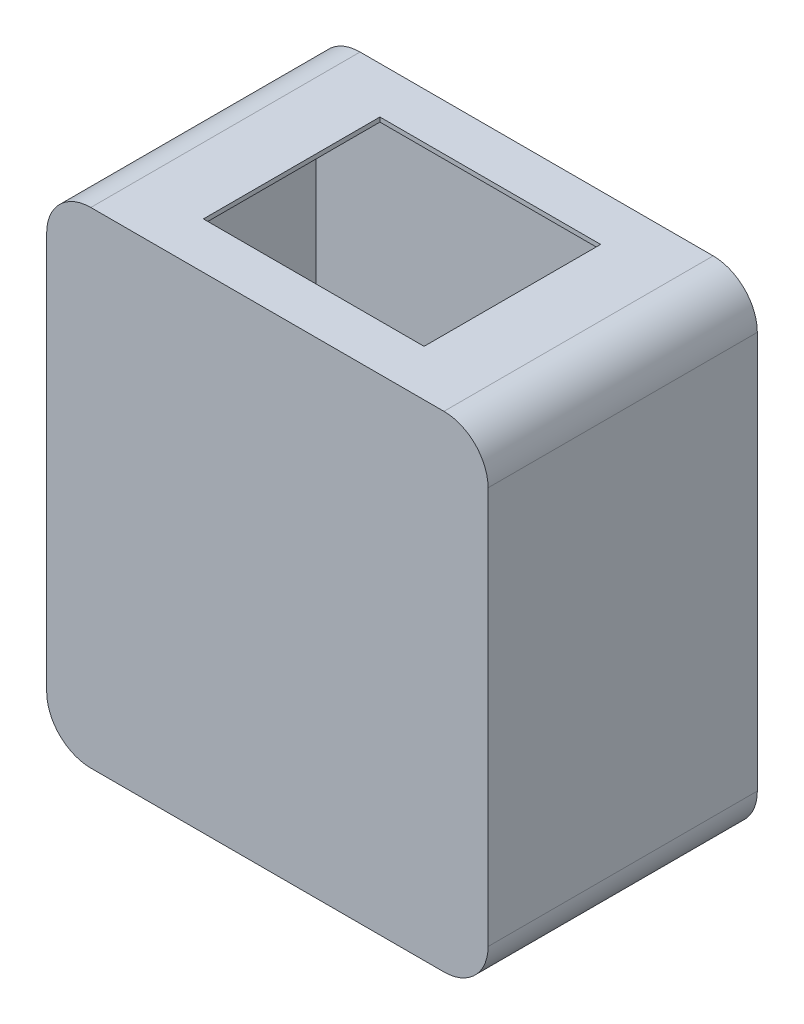
from build123d import *

# Parameters (mm, degrees)
BOSS_EXTRUDE1_DEPTH      = 120
BOSS_EXTRUDE2_DEPTH      = 2
SKETCH4_R                = 3.175
CUT_EXTRUDE2_DEPTH       = 2
SKETCH5_W                = 100
SKETCH5_H                = 80
CUT_EXTRUDE3_DEPTH       = 2
SKETCH6_R                = 3.175
SKETCH6_R_2              = 1.905
BOSS_EXTRUDE3_DEPTH      = 12.7
BOSS_EXTRUDE3_DEPTH_BACK = 2


with BuildPart() as part:
    # Sketch1 → Boss-Extrude1 (new body)
    with BuildSketch(Plane.XY):
        with BuildLine():
            Line((-98.615233931, 126.753710538), (61.384766069, 126.753710538))
            ThreePointArc((61.384766069, 126.753710538), (75.526901693, 120.895846162), (81.384766069, 106.753710538))
            Line((81.384766069, 106.753710538), (81.384766069, -73.246289462))
            ThreePointArc((81.384766069, -73.246289462), (75.526901693, -87.388425086), (61.384766069, -93.246289462))
            Line((61.384766069, -93.246289462), (-98.615233931, -93.246289462))
            ThreePointArc((-98.615233931, -93.246289462), (-112.757369555, -87.388425086), (-118.615233931, -73.246289462))
            Line((-118.615233931, -73.246289462), (-118.615233931, 106.753710538))
            ThreePointArc((-118.615233931, 106.753710538), (-112.757369555, 120.895846162), (-98.615233931, 126.753710538))
        make_face()
        with BuildLine():
            Line((-96.615233931, 124.753710538), (63.384766069, 124.753710538))
            ThreePointArc((63.384766069, 124.753710538), (73.817087779, 119.312661776), (79.384766069, 108.947368421))
            Line((79.384766069, 108.947368421), (79.384766069, -71.052631579))
            ThreePointArc((79.384766069, -71.052631579), (78.377585569, -77.942212595), (75.069516555, -84.068991401))
            Line((75.069516555, -84.068991401), (-16.615233931, -91.246289462))
            Line((-16.615233931, -91.246289462), (-110.826280736, -85.32012324))
            ThreePointArc((-110.826280736, -85.32012324), (-115.148769435, -78.765785158), (-116.615233931, -71.052631579))
            Line((-116.615233931, -71.052631579), (-116.615233931, 104.753710538))
            ThreePointArc((-116.615233931, 104.753710538), (-110.757369555, 118.895846162), (-96.615233931, 124.753710538))
        make_face(mode=Mode.SUBTRACT)
    extrude(amount=BOSS_EXTRUDE1_DEPTH)

    # Sketch2 → Boss-Extrude2 (add)
    with BuildSketch(Plane(origin=(0, 0, 0), x_dir=(-1, 0, 0), z_dir=(0, 0, -1))):
        with BuildLine():
            Line((-81.384766069, -73.246289462), (-81.384766069, 106.753710538))
            ThreePointArc((-81.384766069, 106.753710538), (-75.526901693, 120.895846162), (-61.384766069, 126.753710538))
            Line((-61.384766069, 126.753710538), (98.615233931, 126.753710538))
            ThreePointArc((98.615233931, 126.753710538), (112.757369555, 120.895846162), (118.615233931, 106.753710538))
            Line((118.615233931, 106.753710538), (118.615233931, -73.246289462))
            ThreePointArc((118.615233931, -73.246289462), (112.757369555, -87.388425086), (98.615233931, -93.246289462))
            Line((98.615233931, -93.246289462), (-61.384766069, -93.246289462))
            ThreePointArc((-61.384766069, -93.246289462), (-75.526901693, -87.388425086), (-81.384766069, -73.246289462))
        make_face()
    boss_extrude2 = extrude(amount=BOSS_EXTRUDE2_DEPTH)

    # Mirror1: Boss-Extrude2 across plane
    add(boss_extrude2.mirror(Plane.XY.offset(59)))

    # Sketch4 → Cut-Extrude2 (cut)
    with BuildSketch(Plane(origin=(0, 0, -2), x_dir=(-1, 0, 0), z_dir=(0, 0, -1))):
        with Locations((18.615233931, -88.071289462)):
            Circle(SKETCH4_R)
    extrude(amount=-CUT_EXTRUDE2_DEPTH, mode=Mode.SUBTRACT)

    # Sketch5 → Cut-Extrude3 (cut)
    with BuildSketch(Plane(origin=(0, 126.753710538, 0), x_dir=(1, 0, 0), z_dir=(0, 1, 0))):
        with Locations((-18.615233931, -59)):
            Rectangle(SKETCH5_W, SKETCH5_H)
    extrude(amount=-CUT_EXTRUDE3_DEPTH, mode=Mode.SUBTRACT)


with BuildPart() as body_2:
    # Sketch6 → Boss-Extrude3 (new body, two sides)
    with BuildSketch(Plane(origin=(0, 0, -2), x_dir=(-1, 0, 0), z_dir=(0, 0, -1))) as boss_extrude3_sk:
        with Locations((18.615233931, -88.071289462)):
            Circle(SKETCH6_R)
        with Locations((18.615233931, -88.071289462)):
            Circle(SKETCH6_R_2, mode=Mode.SUBTRACT)
    extrude(amount=BOSS_EXTRUDE3_DEPTH)
    extrude(boss_extrude3_sk.sketch, amount=-BOSS_EXTRUDE3_DEPTH_BACK)


solid = Compound([part.part, body_2.part])
